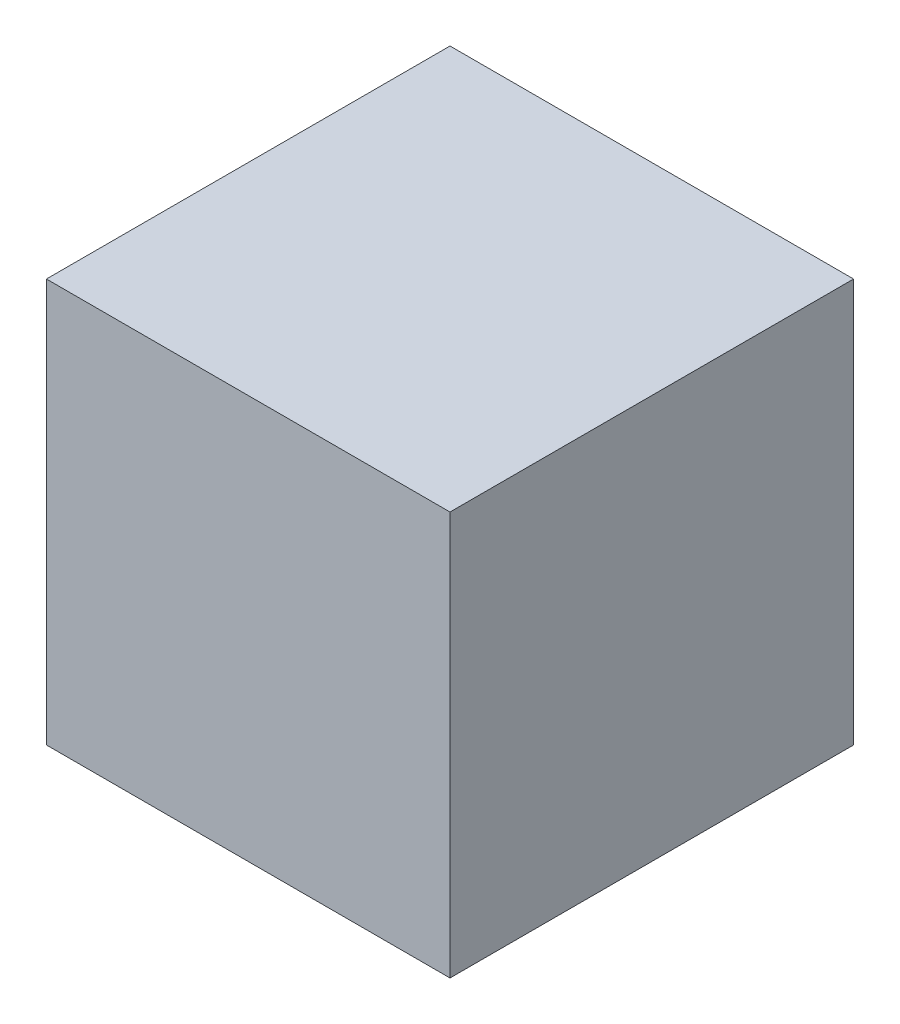
from build123d import *

# Parameters (mm, degrees)
SKETCH1_W           = 7257.1992048
SKETCH1_H           = 7257.1992048
BOSS_EXTRUDE1_DEPTH = 3628.5996024


with BuildPart() as part:
    # Sketch1 → Boss-Extrude1 (new body, symmetric)
    with BuildSketch(Plane.XY):
        Rectangle(SKETCH1_W, SKETCH1_H)
    extrude(amount=BOSS_EXTRUDE1_DEPTH, both=True)


solid = part.part
